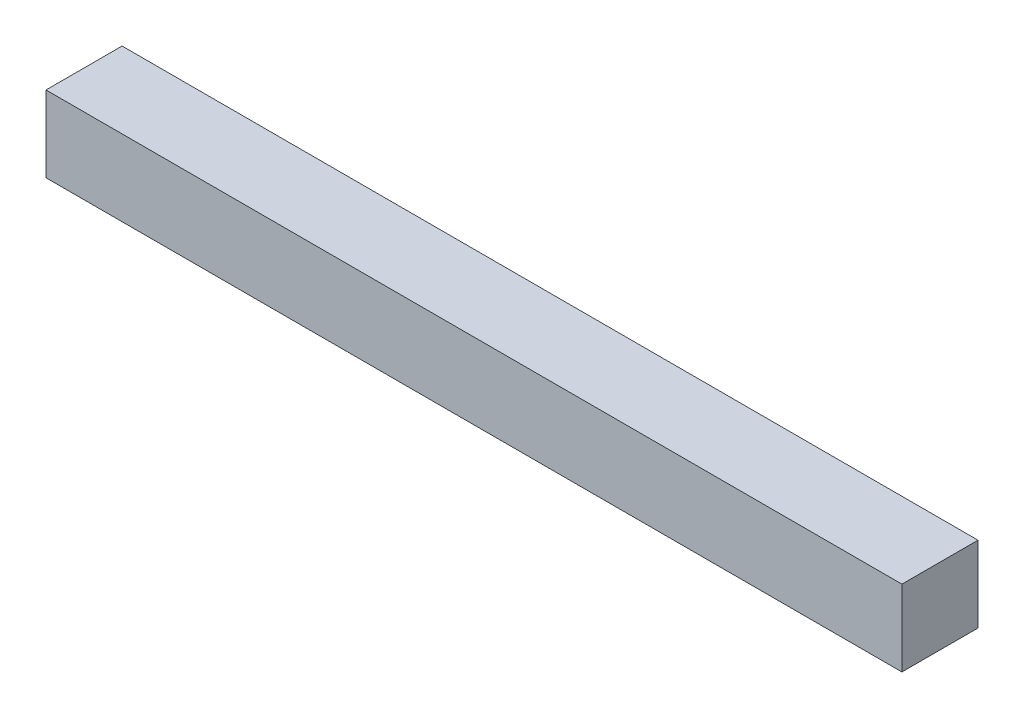
from build123d import *

# Parameters (mm, degrees)
SKETCH_1_W      = 27
SKETCH_1_H      = 2.4
EXTRUDE_1_DEPTH = 2.4


with BuildPart() as part:
    # 草图1 → 凸台-拉伸1 (new body)
    with BuildSketch(Plane(origin=(0, 0, 0), x_dir=(1, 0, 0), z_dir=(0, 1, 0))):
        with Locations((13.5, 1.2)):
            Rectangle(SKETCH_1_W, SKETCH_1_H)
    extrude(amount=EXTRUDE_1_DEPTH)


solid = part.part
